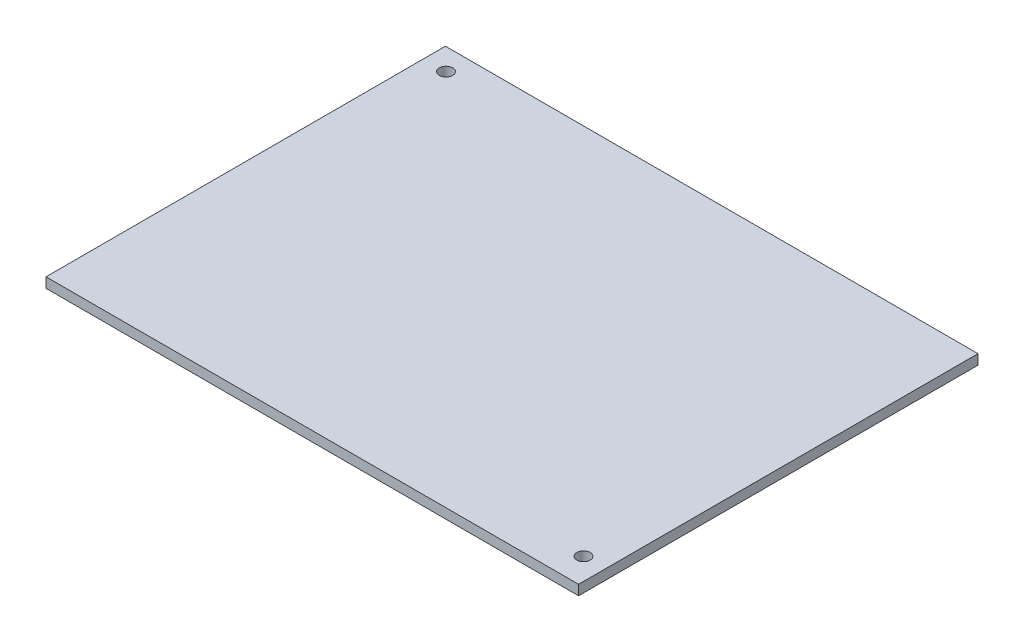
from build123d import *

# Parameters (mm, degrees)
ESQUISSE1_W             = 80
ESQUISSE1_H             = 60
BOSS_EXTRU_1_DEPTH      = 1.5
ESQUISSE3_R             = 1
ENL_V_MAT_EXTRU_1_DEPTH = 1.5


with BuildPart() as part:
    # Esquisse1 → Boss.-Extru.1 (new body)
    with BuildSketch(Plane(origin=(0, 0, 0), x_dir=(1, 0, 0), z_dir=(0, 1, 0))):
        with Locations((40, 30)):
            Rectangle(ESQUISSE1_W, ESQUISSE1_H)
    extrude(amount=BOSS_EXTRU_1_DEPTH)

    # Esquisse3 → Enlèv. mat.-Extru.1 (cut)
    with BuildSketch(Plane(origin=(0, 1.5, 0), x_dir=(1, 0, 0), z_dir=(0, 1, 0))):
        with Locations((3.355347988, 56.733795056)):
            Circle(ESQUISSE3_R)
        with Locations((76.72753532, 4.012087441)):
            Circle(ESQUISSE3_R)
    extrude(amount=-ENL_V_MAT_EXTRU_1_DEPTH, mode=Mode.SUBTRACT)


solid = part.part
